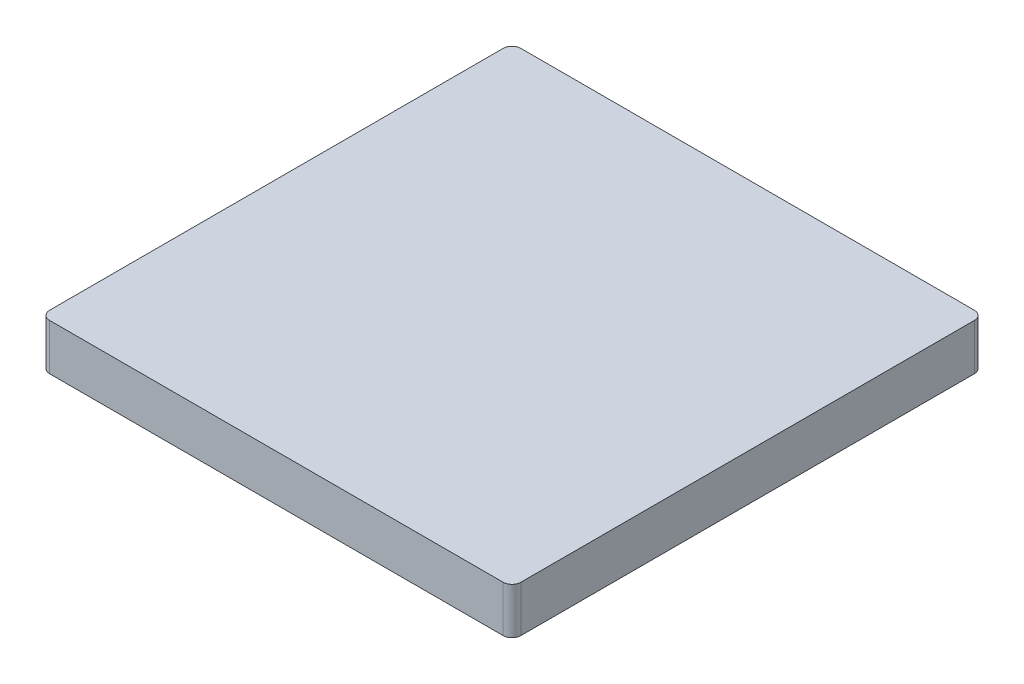
from build123d import *

# Parameters (mm, degrees)
SKETCH1_W           = 16
SKETCH1_H           = 16
BOSS_EXTRUDE1_DEPTH = 1.57
FILLET1_R           = 0.3


with BuildPart() as part:
    # Sketch1 → Boss-Extrude1 (new body)
    with BuildSketch(Plane(origin=(0, 0, 0), x_dir=(1, 0, 0), z_dir=(0, 1, 0))):
        Rectangle(SKETCH1_W, SKETCH1_H)
    extrude(amount=BOSS_EXTRUDE1_DEPTH)

    # Fillet1
    fillet1_edges = [part.edges().sort_by_distance(p)[0] for p in [
        (8, 0.785, 8),
        (-8, 0.785, 8),
        (-8, 0.785, -8),
        (8, 0.785, -8),
    ]]
    fillet(fillet1_edges, radius=FILLET1_R)


solid = part.part
